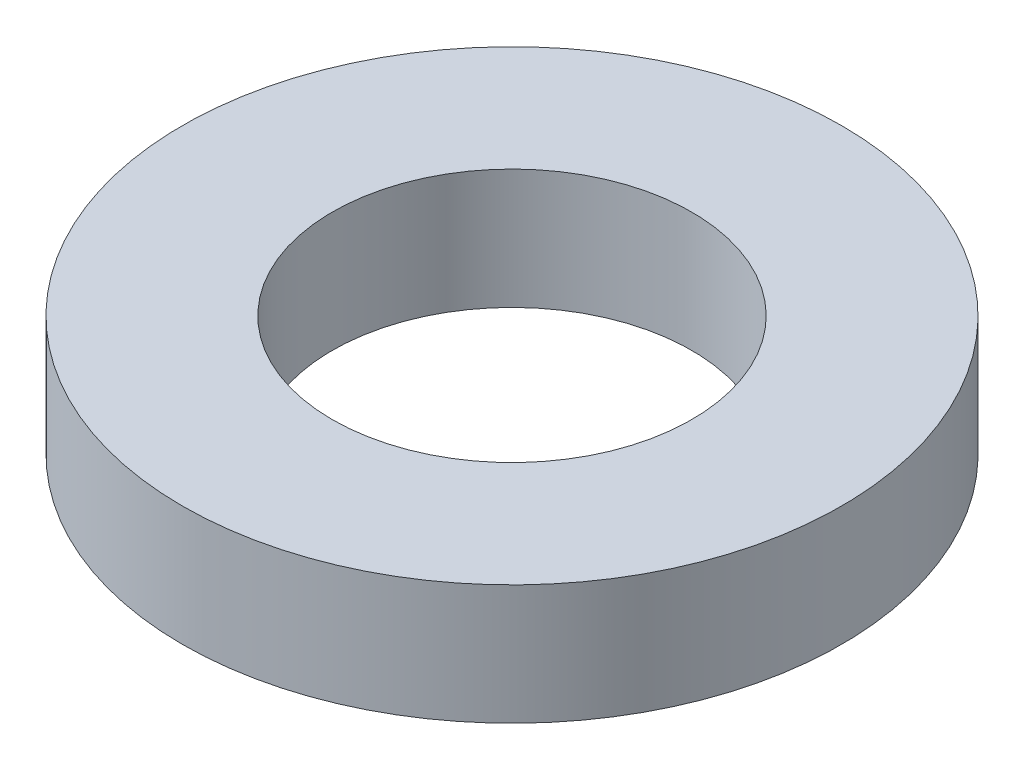
from build123d import *

# Parameters (mm, degrees)
SKETCH1_R           = 2.75
SKETCH1_R_2         = 1.5
BOSS_EXTRUDE1_DEPTH = 1


with BuildPart() as part:
    # Sketch1 → Boss-Extrude1 (new body)
    with BuildSketch(Plane(origin=(0, 0, 0), x_dir=(1, 0, 0), z_dir=(0, 1, 0))):
        Circle(SKETCH1_R)
        Circle(SKETCH1_R_2, mode=Mode.SUBTRACT)
    extrude(amount=BOSS_EXTRUDE1_DEPTH)


solid = part.part
